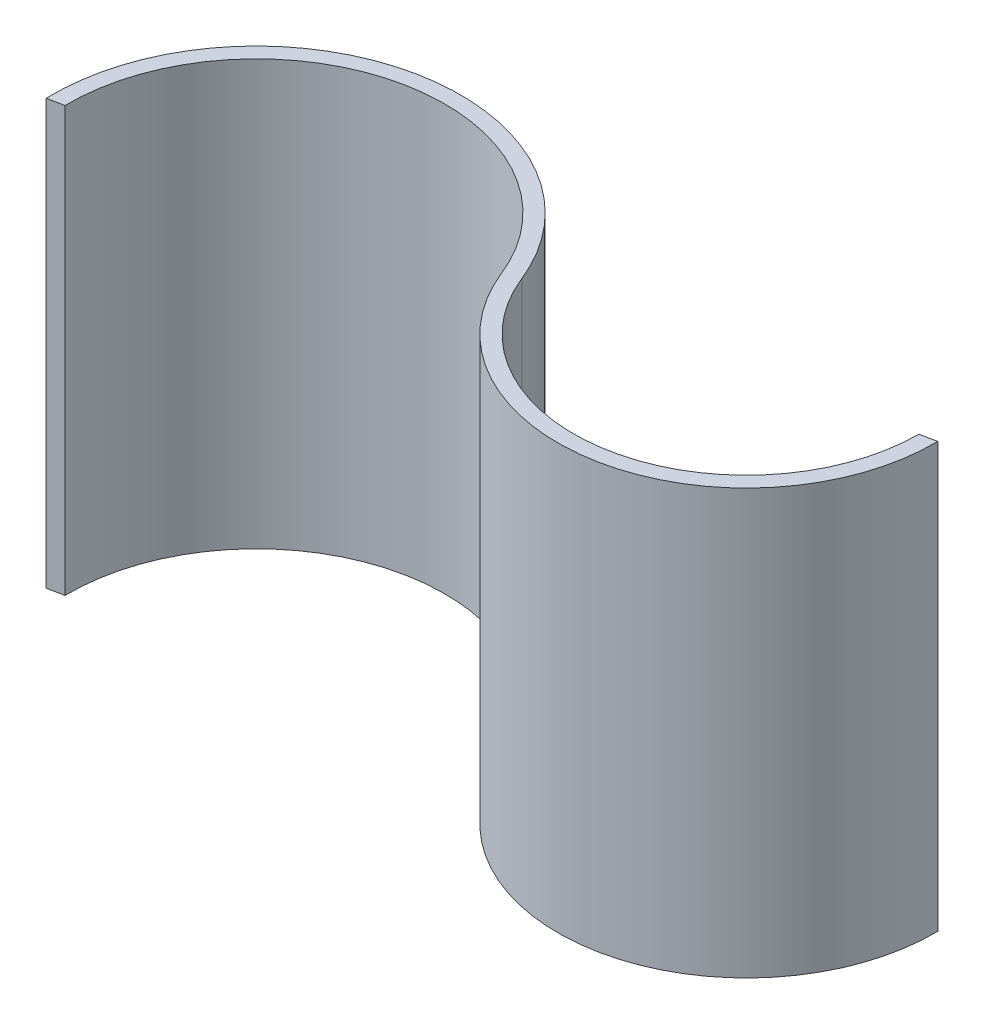
from build123d import *

# Parameters (mm, degrees)
EXTRUDE_1_DEPTH = 135


with BuildPart() as part:
    # Эскиз4 → Бобышка-Вытянуть1 (new body)
    with BuildSketch(Plane(origin=(0, 0, 0), x_dir=(1, 0, 0), z_dir=(0, 1, 0))):
        with BuildLine():
            Line((110.708418771, 22.141683754), (115.702479941, 23.140495988))
            ThreePointArc((115.702479941, 23.140495988), (67.475569561, -36.55139996), (0, 0))
            ThreePointArc((0, 0), (-67.475569561, 36.55139996), (-115.702479941, -23.140495988))
            Line((-115.702479941, -23.140495988), (-120.682183817, -24.136436763))
            ThreePointArc((-120.682183817, -24.136436763), (-68.909214493, 41.362013423), (4.642383454, 1.856953382))
            ThreePointArc((4.642383454, 1.856953382), (66.039906911, -31.737519495), (110.708418771, 22.141683754))
        make_face()
    extrude(amount=EXTRUDE_1_DEPTH)


solid = part.part
